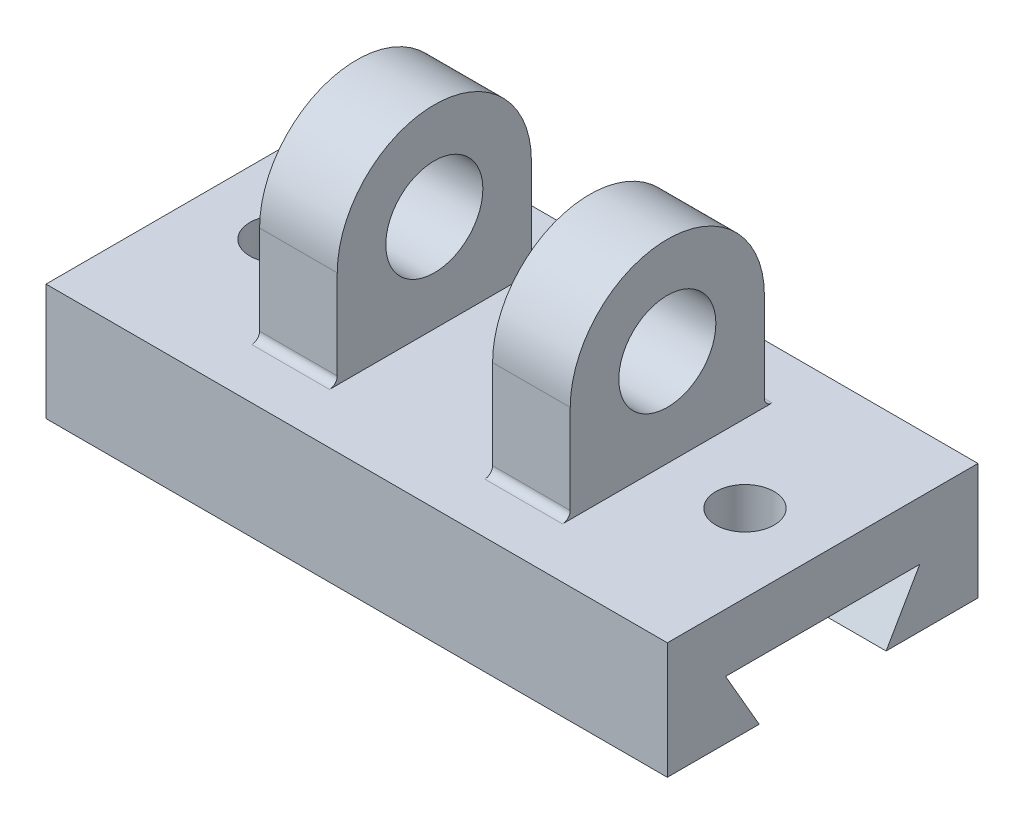
from build123d import *

# Parameters (mm, degrees)
SKETCH2_W           = 160
SKETCH2_H           = 80
BOSS_EXTRUDE1_DEPTH = 30
CUT_EXTRUDE1_DEPTH  = 168.630546142
SKETCH4_R           = 7.5
CUT_EXTRUDE2_DEPTH  = 95.339811321
BOSS_EXTRUDE2_START = -40
SKETCH5_R           = 12.5
BOSS_EXTRUDE2_DEPTH = 20
FILLET1_R           = 2


with BuildPart() as part:
    # Sketch2 → Boss-Extrude1 (new body)
    with BuildSketch(Plane(origin=(0, 0, 0), x_dir=(1, 0, 0), z_dir=(0, 1, 0))):
        Rectangle(SKETCH2_W, SKETCH2_H)
    extrude(amount=BOSS_EXTRUDE1_DEPTH)

    # Sketch3 → Cut-Extrude1 (cut, through all)
    with BuildSketch(Plane(origin=(80, 0, 0), x_dir=(0, 0, -1), z_dir=(1, 0, 0))):
        Polygon((-25, 15), (-16.339745962, 0), (16.339745962, 0), (25, 15), align=None)
    extrude(amount=-CUT_EXTRUDE1_DEPTH, mode=Mode.SUBTRACT)

    # Sketch4 → Cut-Extrude2 (cut, through all)
    with BuildSketch(Plane(origin=(0, 30, 0), x_dir=(1, 0, 0), z_dir=(0, 1, 0))):
        with Locations(Location((60, 0, 0), (0, 0, 270))):
            Circle(SKETCH4_R)
    cut_extrude2 = extrude(amount=-CUT_EXTRUDE2_DEPTH, mode=Mode.SUBTRACT)

    # Sketch5 → Boss-Extrude2 (add)
    with BuildSketch(Plane(origin=(80, 0, 0), x_dir=(0, 0, -1), z_dir=(1, 0, 0)).offset(BOSS_EXTRUDE2_START)):
        with BuildLine():
            ThreePointArc((25, 55), (0, 80), (-25, 55))
            Line((-25, 55), (-25, 30))
            Line((-25, 30), (25, 30))
            Line((25, 30), (25, 55))
        make_face()
        with Locations((0, 55)):
            Circle(SKETCH5_R, mode=Mode.SUBTRACT)
    boss_extrude2 = extrude(amount=-BOSS_EXTRUDE2_DEPTH)

    # Mirror1: Cut-Extrude2, Boss-Extrude2 across plane
    add(cut_extrude2.mirror(Plane(origin=(0, 0, 0), x_dir=(0, 0, 1), z_dir=(1, 0, 0))), mode=Mode.SUBTRACT)
    add(boss_extrude2.mirror(Plane(origin=(0, 0, 0), x_dir=(0, 0, 1), z_dir=(1, 0, 0))))

    # Fillet1
    fillet1_edges = [part.edges().sort_by_distance(p)[0] for p in [
        (30, 30, -25),
        (30, 30, 25),
        (-30, 30, 25),
        (-30, 30, -25),
    ]]
    fillet(fillet1_edges, radius=FILLET1_R)


solid = part.part
